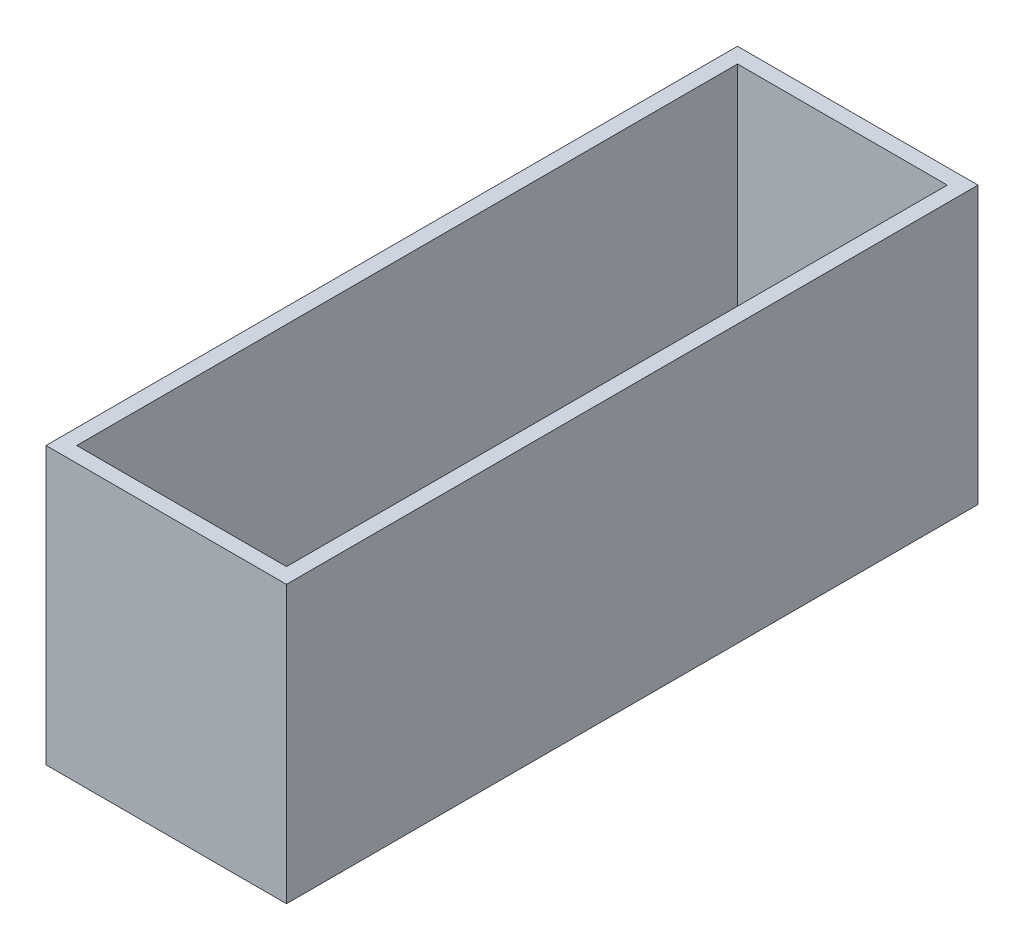
from build123d import *

# Parameters (mm, degrees)
SKETCH2_W           = 156.5
SKETCH2_H           = 180
BOSS_EXTRUDE1_DEPTH = 450
SKETCH3_W           = 136.5
SKETCH3_H           = 430
CUT_EXTRUDE1_DEPTH  = 160


with BuildPart() as part:
    # Sketch2 → Boss-Extrude1 (new body)
    with BuildSketch(Plane.XY):
        Rectangle(SKETCH2_W, SKETCH2_H)
    extrude(amount=BOSS_EXTRUDE1_DEPTH)

    # Sketch3 → Cut-Extrude1 (cut)
    with BuildSketch(Plane(origin=(0, 90, 0), x_dir=(1, 0, 0), z_dir=(0, 1, 0))):
        with Locations((0, -225)):
            Rectangle(SKETCH3_W, SKETCH3_H)
    extrude(amount=-CUT_EXTRUDE1_DEPTH, mode=Mode.SUBTRACT)


solid = part.part
